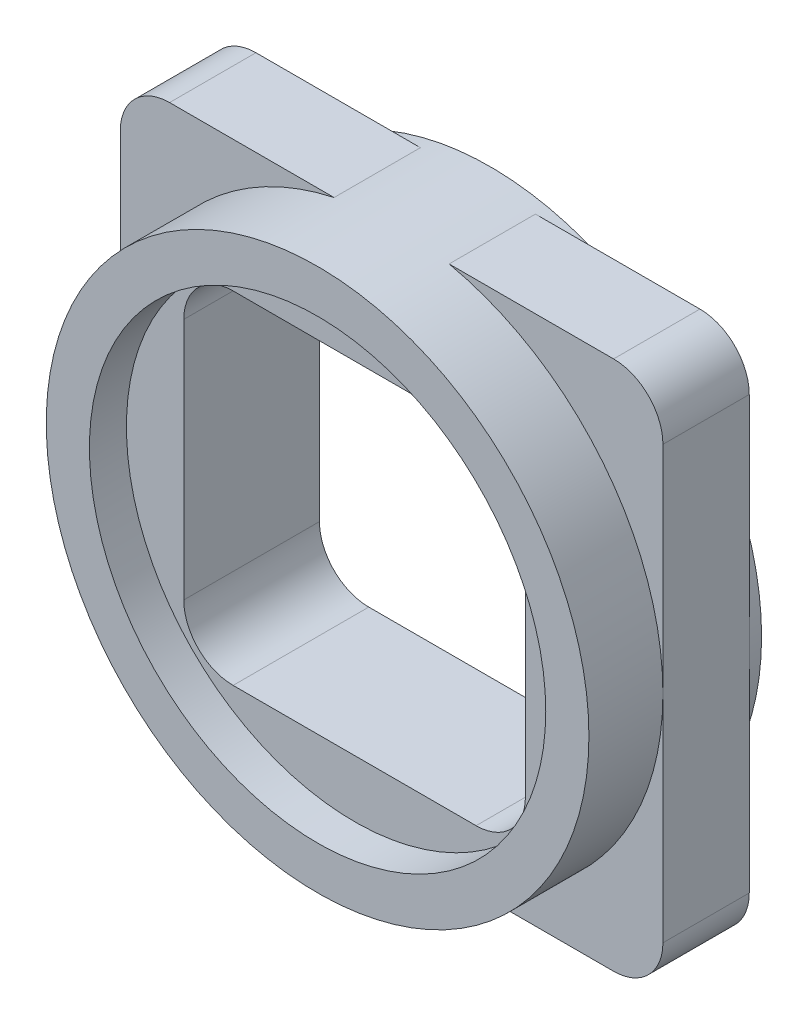
from build123d import *

# Parameters (mm, degrees)
SKETCH1_W                = 37.5
SKETCH1_H                = 40.9
SKETCH1_W_2              = 27.7
SKETCH1_H_2              = 27.7
BOSS_EXTRUDE1_DEPTH      = 6
SKETCH4_W                = 16.432066976
SKETCH4_H                = 47.432770651
CUT_EXTRUDE1_DEPTH       = 46
SKETCH5_W                = 44
SKETCH5_H                = 43
BOSS_EXTRUDE2_DEPTH      = 1
CUT_EXTRUDE2_DEPTH       = 1
SKETCH7_W                = 44
SKETCH7_H                = 43
SKETCH7_W_2              = 37.866148728
SKETCH7_H_2              = 40.8
BOSS_EXTRUDE3_DEPTH      = 6
FILLET1_R                = 4
SKETCH8_R                = 22
BOSS_EXTRUDE4_DEPTH      = 3
BOSS_EXTRUDE4_DEPTH_BACK = 8
SKETCH9_R                = 22
SKETCH9_R_2              = 18.5
BOSS_EXTRUDE5_DEPTH      = 3


with BuildPart() as part:
    # Sketch1 → Boss-Extrude1 (new body)
    with BuildSketch(Plane.XY):
        with Locations((13.85, -13.85)):
            Rectangle(SKETCH1_W, SKETCH1_H)
        with Locations((13.85, -13.85)):
            Rectangle(SKETCH1_W_2, SKETCH1_H_2, mode=Mode.SUBTRACT)
    extrude(amount=BOSS_EXTRUDE1_DEPTH)

    # Sketch4 → Cut-Extrude1 (cut)
    with BuildSketch(Plane.ZY.offset(4.9)):
        with Locations((3.592909633, -13.002986239)):
            Rectangle(SKETCH4_W, SKETCH4_H)
        with BuildLine():
            Line((0, 3.6), (0, -31.3))
            ThreePointArc((0, -31.3), (3, -34.3), (6, -31.3))
            Line((6, -31.3), (6, 3.6))
            ThreePointArc((6, 3.6), (3, 6.6), (0, 3.6))
        make_face(mode=Mode.SUBTRACT)
    extrude(amount=-CUT_EXTRUDE1_DEPTH, mode=Mode.SUBTRACT)

    # Sketch5 → Boss-Extrude2 (add)
    with BuildSketch(Plane.XY.offset(6)):
        with Locations((13.85, -13.85)):
            Rectangle(SKETCH5_W, SKETCH5_H)
    extrude(amount=BOSS_EXTRUDE2_DEPTH)

    # Sketch6 → Cut-Extrude2 (cut)
    with BuildSketch(Plane.XY.offset(7)):
        with BuildLine():
            Line((4, -27.7), (23.7, -27.7))
            ThreePointArc((23.7, -27.7), (26.528427125, -26.528427125), (27.7, -23.7))
            Line((27.7, -23.7), (27.7, -4))
            ThreePointArc((27.7, -4), (26.528427125, -1.171572875), (23.7, 0))
            Line((23.7, 0), (4, 0))
            ThreePointArc((4, 0), (1.171572875, -1.171572875), (0, -4))
            Line((0, -4), (0, -23.7))
            ThreePointArc((0, -23.7), (1.171572875, -26.528427125), (4, -27.7))
        make_face()
    extrude(amount=-CUT_EXTRUDE2_DEPTH, mode=Mode.SUBTRACT)

    # Sketch7 → Boss-Extrude3 (add)
    with BuildSketch(Plane(origin=(0, 0, 6), x_dir=(-1, 0, 0), z_dir=(0, 0, -1))):
        with Locations((-13.85, -13.85)):
            Rectangle(SKETCH7_W, SKETCH7_H)
        with Locations((-13.85, -13.85)):
            Rectangle(SKETCH7_W_2, SKETCH7_H_2, mode=Mode.SUBTRACT)
    extrude(amount=BOSS_EXTRUDE3_DEPTH)

    # Fillet1
    fillet1_edges = [part.edges().sort_by_distance(p)[0] for p in [
        (35.85, -35.35, 3.5),
        (35.85, 7.65, 3.5),
        (-8.15, 7.65, 3.5),
        (-8.15, -35.35, 3.5),
    ]]
    fillet(fillet1_edges, radius=FILLET1_R)

    # Sketch8 → Boss-Extrude4 (add, two sides)
    with BuildSketch(Plane.XY.offset(7)) as boss_extrude4_sk:
        with Locations((13.85, -13.85)):
            Circle(SKETCH8_R)
        with BuildLine():
            Line((27.7, -23.7), (27.7, -4))
            ThreePointArc((27.7, -4), (26.528427125, -1.171572875), (23.7, 0))
            Line((23.7, 0), (4, 0))
            ThreePointArc((4, 0), (1.171572875, -1.171572875), (0, -4))
            Line((0, -4), (0, -23.7))
            ThreePointArc((0, -23.7), (1.171572875, -26.528427125), (4, -27.7))
            Line((4, -27.7), (23.7, -27.7))
            ThreePointArc((23.7, -27.7), (26.528427125, -26.528427125), (27.7, -23.7))
        make_face(mode=Mode.SUBTRACT)
    extrude(amount=BOSS_EXTRUDE4_DEPTH)
    extrude(boss_extrude4_sk.sketch, amount=-BOSS_EXTRUDE4_DEPTH_BACK)

    # Sketch9 → Boss-Extrude5 (add)
    with BuildSketch(Plane.XY.offset(10)):
        with Locations((13.85, -13.85)):
            Circle(SKETCH9_R)
        with Locations((13.85, -13.85)):
            Circle(SKETCH9_R_2, mode=Mode.SUBTRACT)
    extrude(amount=BOSS_EXTRUDE5_DEPTH)


solid = part.part
